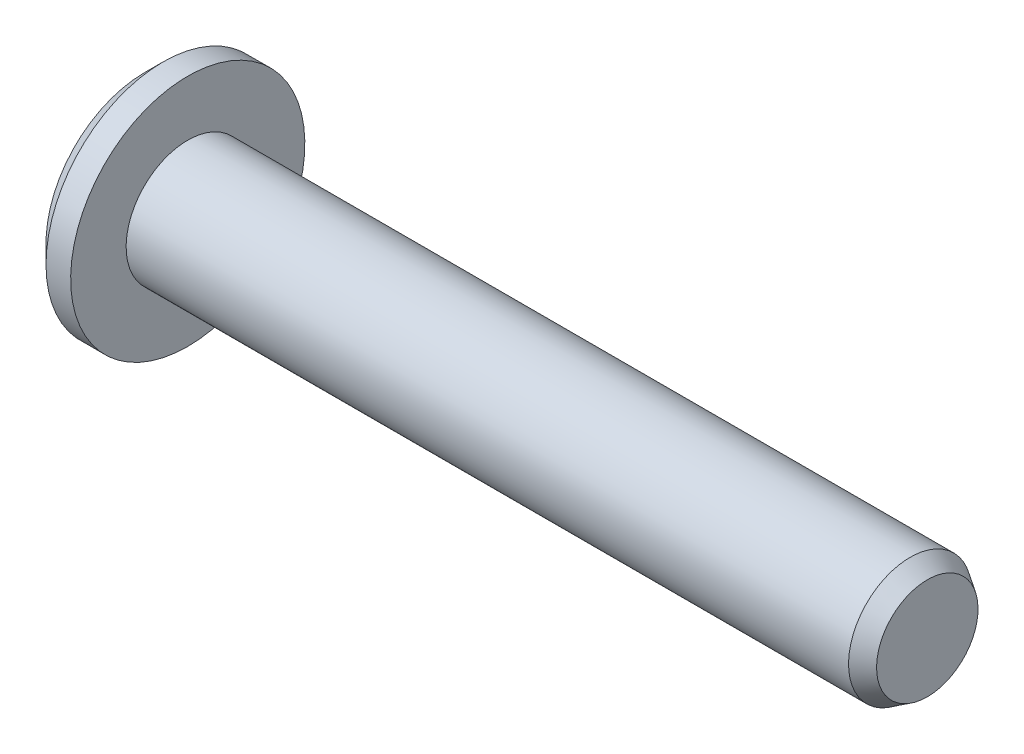
from build123d import *

# Parameters (mm, degrees)
CUT_EXTRUDE1_DEPTH = 1
CHAMFER1_SIZE      = 0.75


with BuildPart() as part:
    # Sketch1 → Revolve1 (revolve)
    with BuildSketch(Plane.XY):
        Polygon((31.75, 0), (31.75, 2.057236169), (31.055, 2.5), (1.75, 2.5), (1.75, 4.75), (0, 4.75), (0, 0), align=None)
    revolve(axis=Axis((0, 0, 0), (1, 0, 0)))

    # Sketch5 → Cut-Extrude1 (cut)
    with BuildSketch(Plane.ZY):
        Polygon((1.5, -0.866025404), (1.5, 0.866025404), (0, 1.732050808), (-1.5, 0.866025404), (-1.5, -0.866025404), (0, -1.732050808), align=None)
    extrude(amount=-CUT_EXTRUDE1_DEPTH, mode=Mode.SUBTRACT)

    # Chamfer1
    chamfer1_edges = [part.edges().sort_by_distance(p)[0] for p in [
        (0, -4.75, 0),
    ]]
    chamfer(chamfer1_edges, length=CHAMFER1_SIZE)


solid = part.part
